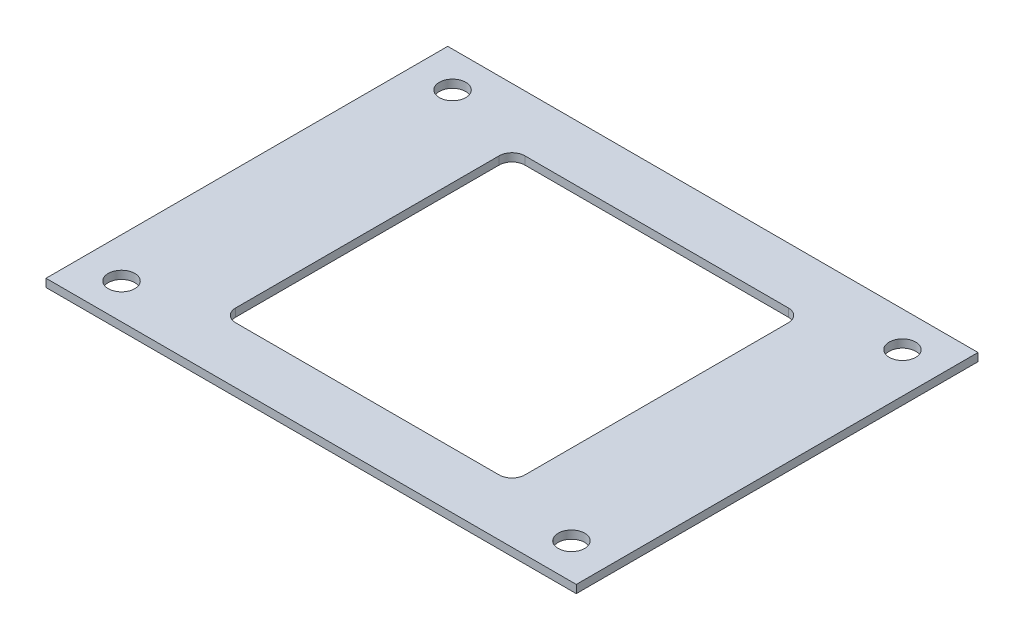
from build123d import *

# Parameters (mm, degrees)
SKETCH1_W           = 66
SKETCH1_H           = 50
SKETCH1_R           = 1.65
SKETCH1_W_2         = 36
SKETCH1_H_2         = 36
BOSS_EXTRUDE1_DEPTH = 1
FILLET1_R           = 1.6


with BuildPart() as part:
    # Sketch1 → Boss-Extrude1 (new body)
    with BuildSketch(Plane(origin=(0, 0, 0), x_dir=(1, 0, 0), z_dir=(0, 1, 0))):
        Rectangle(SKETCH1_W, SKETCH1_H)
        with Locations((-28, 20.6)):
            Circle(SKETCH1_R, mode=Mode.SUBTRACT)
        with Locations((-28, -20.6)):
            Circle(SKETCH1_R, mode=Mode.SUBTRACT)
        with Locations((28, 20.6)):
            Circle(SKETCH1_R, mode=Mode.SUBTRACT)
        with Locations((28, -20.6)):
            Circle(SKETCH1_R, mode=Mode.SUBTRACT)
        Rectangle(SKETCH1_W_2, SKETCH1_H_2, mode=Mode.SUBTRACT)
    extrude(amount=BOSS_EXTRUDE1_DEPTH)

    # Fillet1
    fillet1_edges = [part.edges().sort_by_distance(p)[0] for p in [
        (18, 0.5, 18),
        (18, 0.5, -18),
        (-18, 0.5, -18),
        (-18, 0.5, 18),
    ]]
    fillet(fillet1_edges, radius=FILLET1_R)


solid = part.part
